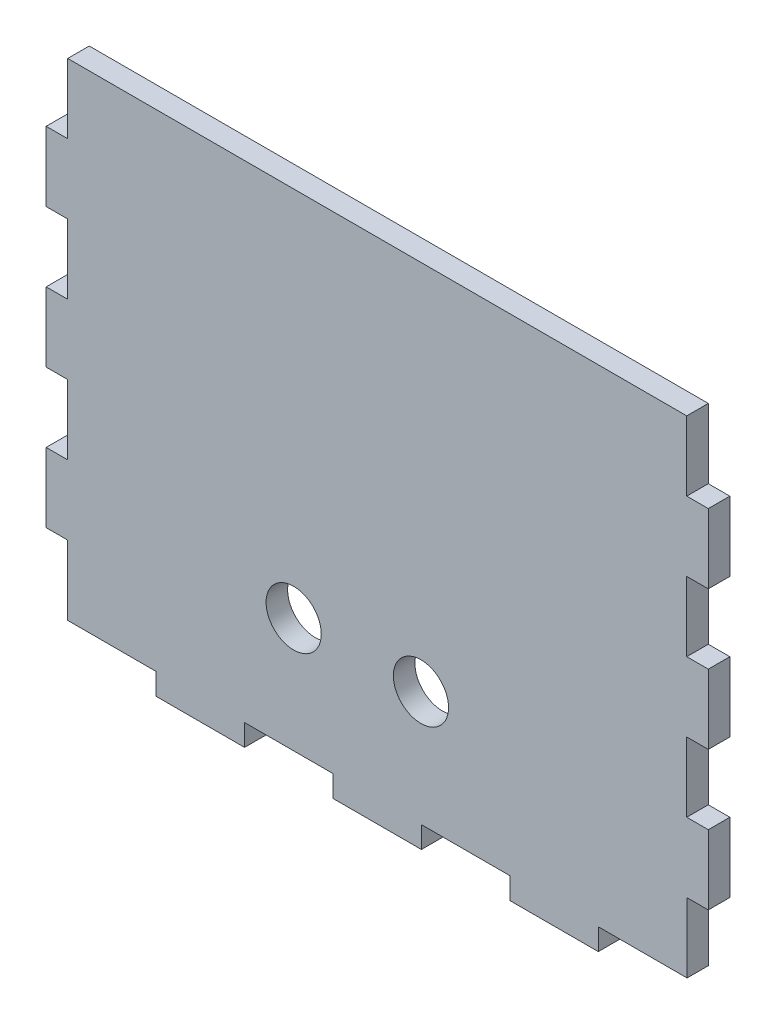
from build123d import *

# Parameters (mm, degrees)
BOSS_EXTRUDE1_DEPTH = 3
SKETCH2_R           = 3.841087015
CUT_EXTRUDE1_DEPTH  = 3


with BuildPart() as part:
    # Sketch1 → Boss-Extrude1 (new body)
    with BuildSketch(Plane.XY):
        Polygon((-37.70901952, -17.564925379), (-25.400175445, -17.564925379), (-25.400175445, -20.564925379), (-13.09133137, -20.564925379), (-13.09133137, -17.564925379), (-0.782487296, -17.564925379), (-0.782487296, -20.564925379), (11.526356779, -20.564925379), (11.526356779, -17.564925379), (23.835200854, -17.564925379), (23.835200854, -20.564925379), (36.144044929, -20.564925379), (36.144044929, -17.564925379), (48.500170095, -17.564925379), (48.500170095, -7.888062048), (51.452889003, -7.888062048), (51.452889003, 1.788801284), (48.452889003, 1.788801284), (48.452889003, 11.465664615), (51.452889003, 11.465664615), (51.452889003, 21.142527947), (48.452889003, 21.142527947), (48.452889003, 30.819391278), (51.452889003, 30.819391278), (51.452889003, 40.49625461), (48.452889003, 40.49625461), (48.452889003, 50.173117941), (-37.70901952, 50.173117941), (-37.70901952, 40.49625461), (-40.70901952, 40.49625461), (-40.70901952, 30.819391278), (-37.70901952, 30.819391278), (-37.70901952, 21.142527947), (-40.70901952, 21.142527947), (-40.70901952, 11.465664615), (-37.70901952, 11.465664615), (-37.70901952, 1.788801284), (-40.70901952, 1.788801284), (-40.70901952, -7.888062048), (-37.70901952, -7.888062048), align=None)
    extrude(amount=BOSS_EXTRUDE1_DEPTH)

    # Sketch2 → Cut-Extrude1 (cut)
    with BuildSketch(Plane.XY.offset(3)):
        with Locations((-6.25812843, -1.568095487)):
            Circle(SKETCH2_R)
        with Locations((11.456834914, -1.568095487)):
            Circle(SKETCH2_R)
    extrude(amount=-CUT_EXTRUDE1_DEPTH, mode=Mode.SUBTRACT)


solid = part.part
